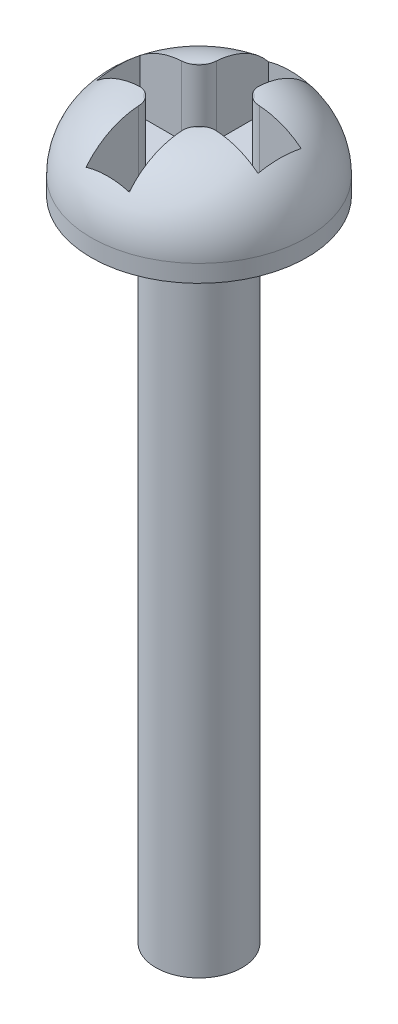
from build123d import *

# Parameters (mm, degrees)
SKETCH1_R           = 1.27
BOSS_EXTRUDE1_DEPTH = 9.525
SKETCH2_R           = 3.175
BOSS_EXTRUDE2_DEPTH = 2.54
FILLET1_R           = 2.032
CUT_EXTRUDE1_DEPTH  = 2.032


with BuildPart() as part:
    # Sketch1 → Boss-Extrude1 (new body, symmetric)
    with BuildSketch(Plane(origin=(0, 0, 0), x_dir=(1, 0, 0), z_dir=(0, 1, 0))):
        Circle(SKETCH1_R)
    extrude(amount=BOSS_EXTRUDE1_DEPTH, both=True)

    # Sketch2 → Boss-Extrude2 (add)
    with BuildSketch(Plane(origin=(0, 9.525, 0), x_dir=(1, 0, 0), z_dir=(0, 1, 0))):
        Circle(SKETCH2_R)
    extrude(amount=BOSS_EXTRUDE2_DEPTH)

    # Fillet1
    fillet1_edges = [part.edges().sort_by_distance(p)[0] for p in [
        (-3.175, 12.065, 0),
    ]]
    fillet(fillet1_edges, radius=FILLET1_R)

    # Sketch3 → Cut-Extrude1 (cut)
    with BuildSketch(Plane(origin=(0, 12.065, 0), x_dir=(1, 0, 0), z_dir=(0, 1, 0))):
        with BuildLine():
            Line((-0.635, 1.143), (-0.635, 2.685389765))
            Line((-0.635, 2.685389765), (0.635, 2.685389765))
            Line((0.635, 2.685389765), (0.635, 1.143))
            ThreePointArc((0.635, 1.143), (0.783789755, 0.783789755), (1.143, 0.635))
            Line((1.143, 0.635), (2.371299226, 0.635))
            Line((2.371299226, 0.635), (2.371299226, -0.635))
            Line((2.371299226, -0.635), (1.143, -0.635))
            ThreePointArc((1.143, -0.635), (0.783789755, -0.783789755), (0.635, -1.143))
            Line((0.635, -1.143), (0.635, -2.685389765))
            Line((0.635, -2.685389765), (-0.635, -2.685389765))
            Line((-0.635, -2.685389765), (-0.635, -1.143))
            ThreePointArc((-0.635, -1.143), (-0.783789755, -0.783789755), (-1.143, -0.635))
            Line((-1.143, -0.635), (-2.371299226, -0.635))
            Line((-2.371299226, -0.635), (-2.371299226, 0.635))
            Line((-2.371299226, 0.635), (-1.143, 0.635))
            ThreePointArc((-1.143, 0.635), (-0.783789755, 0.783789755), (-0.635, 1.143))
        make_face()
    extrude(amount=-CUT_EXTRUDE1_DEPTH, mode=Mode.SUBTRACT)


solid = part.part
